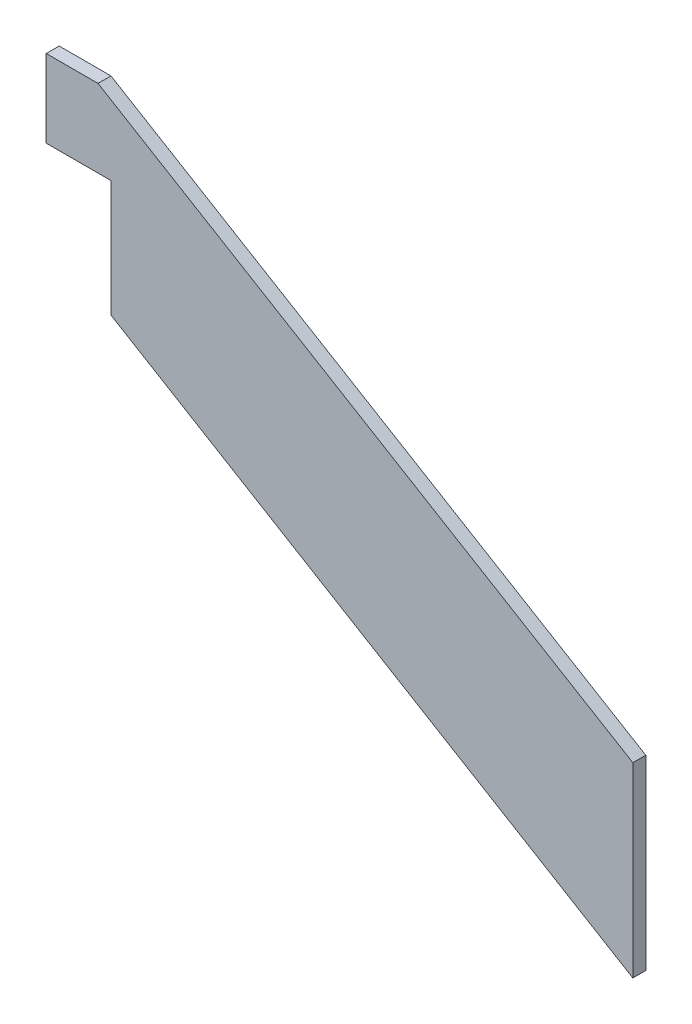
from build123d import *

# Parameters (mm, degrees)
BOSS_EXTRU_1_DEPTH = 1


with BuildPart() as part:
    # Esquisse1 → Boss.-Extru.1 (new body)
    with BuildSketch(Plane.XY):
        Polygon((0, 0), (-40.302167508, 24.181300505), (-40.302167508, 33.181300505), (-45.302167508, 33.181300505), (-45.302167508, 39.181300505), (-41.302167508, 39.181300505), (0, 14.4), align=None)
    extrude(amount=BOSS_EXTRU_1_DEPTH)


solid = part.part
